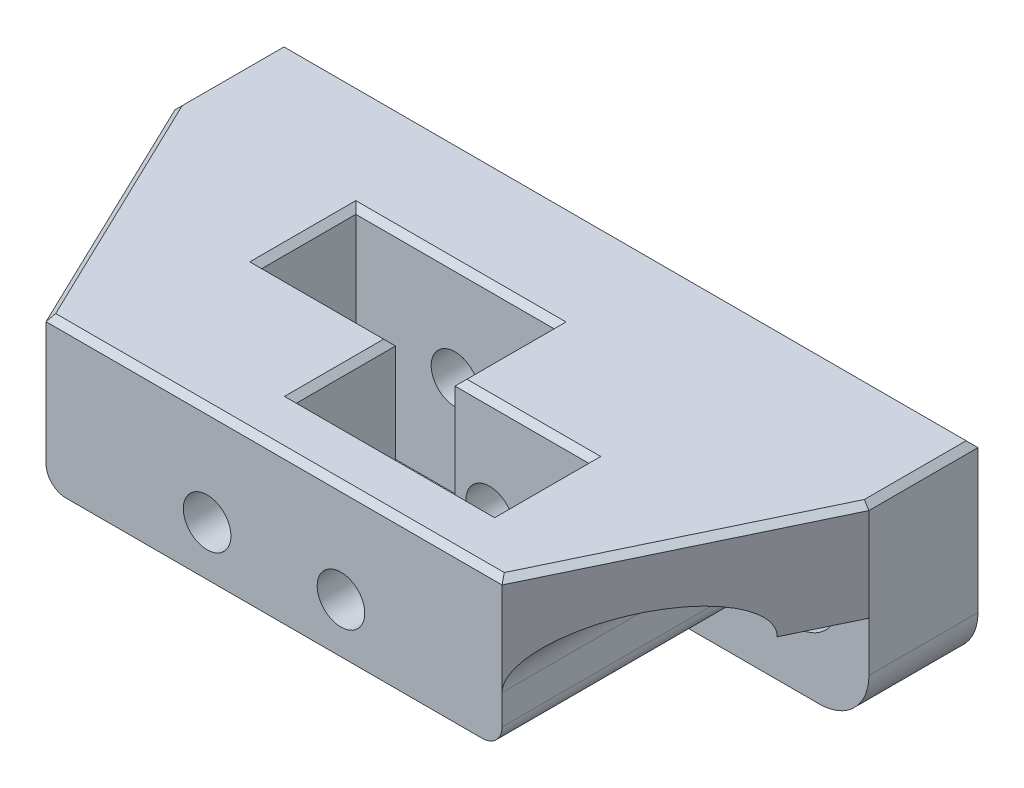
from build123d import *

# Parameters (mm, degrees)
SKETCH_1_W               = 70
SKETCH_1_H               = 20
EXTRUDE_1_DEPTH          = 11
SKETCH_3_W               = 70
SKETCH_3_H               = 15
EXTRUDE_2_DEPTH          = 25
CUT_EXTRUDE_1_DEPTH      = 15
SKETCH_5_R               = 4.5
CUT_EXTRUDE_2_DEPTH      = 30
SKETCH_11_R              = 2.6
CUT_EXTRUDE_7_DEPTH      = 6
SKETCH_12_W              = 12
SKETCH_12_H              = 5
CUT_EXTRUDE_8_DEPTH      = 25
SKETCH_8_R               = 2.4
CUT_EXTRUDE_5_DEPTH      = 31.5
CUT_EXTRUDE_5_DEPTH_BACK = 6.5
SKETCH_10_R              = 2.4
CUT_EXTRUDE_6_DEPTH      = 26
CUT_EXTRUDE_6_DEPTH_BACK = 12
FILLET_1_R               = 5
CHAMFER_1_SIZE           = 0.6
FILLET_2_R               = 2


with BuildPart() as part:
    # 草图1 → 凸台-拉伸1 (new body)
    with BuildSketch(Plane.XY):
        with Locations((21.875, 8.541666667)):
            Rectangle(SKETCH_1_W, SKETCH_1_H)
    extrude(amount=EXTRUDE_1_DEPTH)

    # 草图3 → 凸台-拉伸2 (add)
    with BuildSketch(Plane.XY.offset(11)):
        with Locations((21.875, 11.041666667)):
            Rectangle(SKETCH_3_W, SKETCH_3_H)
    extrude(amount=EXTRUDE_2_DEPTH)

    # 草图4 → 切除-拉伸1 (cut)
    with BuildSketch(Plane.XZ.offset(-3.541666667)):
        Polygon((-13.125, 36), (-13.125, 11), (-1.125, 36), align=None)
        Polygon((56.875, 11), (44.875, 36), (56.875, 36), align=None)
        Polygon((5.125, 11), (25.125, 11), (25.125, 21), (38.625, 21), (38.625, 30.5), (18.625, 30.5), (18.625, 21), (18.625, 20.5), (5.125, 20.5), align=None)
    extrude(amount=-CUT_EXTRUDE_1_DEPTH, mode=Mode.SUBTRACT)

    # 草图5 → 切除-拉伸2 (cut)
    with BuildSketch(Plane.XY.offset(36)):
        with Locations((-5.625, 8.541666667)):
            Circle(SKETCH_5_R)
        with Locations((49.375, 8.541666667)):
            Circle(SKETCH_5_R)
    extrude(amount=-CUT_EXTRUDE_2_DEPTH, mode=Mode.SUBTRACT)

    # 草图11 → 切除-拉伸7 (cut)
    with BuildSketch(Plane.XY.offset(6)):
        with Locations((-5.625, 8.541666667)):
            Circle(SKETCH_11_R)
        with Locations((49.375, 8.541666667)):
            Circle(SKETCH_11_R)
    extrude(amount=-CUT_EXTRUDE_7_DEPTH, mode=Mode.SUBTRACT)

    # 草图12 → 切除-拉伸8 (cut)
    with BuildSketch(Plane.XY.offset(36)):
        with Locations((-7.125, 6.041666667)):
            Rectangle(SKETCH_12_W, SKETCH_12_H)
        with Locations((50.875, 6.041666667)):
            Rectangle(SKETCH_12_W, SKETCH_12_H)
    extrude(amount=-CUT_EXTRUDE_8_DEPTH, mode=Mode.SUBTRACT)

    # 草图8 → 切除-拉伸5 (cut, two sides)
    with BuildSketch(Plane(origin=(0, 0, 30.5), x_dir=(-1, 0, 0), z_dir=(0, 0, -1))) as cut_extrude_5_sk:
        with Locations((-28.625, 8.541666667)):
            Circle(SKETCH_8_R)
    extrude(amount=CUT_EXTRUDE_5_DEPTH, mode=Mode.SUBTRACT)
    extrude(cut_extrude_5_sk.sketch, amount=-CUT_EXTRUDE_5_DEPTH_BACK, mode=Mode.SUBTRACT)

    # 草图10 → 切除-拉伸6 (cut, two sides)
    with BuildSketch(Plane.XY.offset(11)) as cut_extrude_6_sk:
        with Locations((15.125, 8.541666667)):
            Circle(SKETCH_10_R)
    extrude(amount=CUT_EXTRUDE_6_DEPTH, mode=Mode.SUBTRACT)
    extrude(cut_extrude_6_sk.sketch, amount=-CUT_EXTRUDE_6_DEPTH_BACK, mode=Mode.SUBTRACT)

    # 圆角1
    fillet_1_edges = [part.edges().sort_by_distance(p)[0] for p in [
        (56.875, -1.458333333, 5.5),
        (-13.125, -1.458333333, 5.5),
    ]]
    fillet(fillet_1_edges, radius=FILLET_1_R)

    # 倒角1
    chamfer_1_edges = [part.edges().sort_by_distance(p)[0] for p in [
        (21.875, 18.541666667, 36),
        (-13.125, 18.541666667, 5.5),
        (56.875, 18.541666667, 5.5),
        (-7.125, 18.541666667, 23.5),
        (50.875, 18.541666667, 23.5),
        (5.125, 18.541666667, 15.75),
        (11.875, 18.541666667, 20.5),
        (18.625, 18.541666667, 25.5),
        (21.875, 18.541666667, 0),
        (28.625, 18.541666667, 30.5),
        (38.625, 18.541666667, 25.75),
        (31.875, 18.541666667, 21),
        (25.125, 18.541666667, 16),
        (15.125, 18.541666667, 11),
    ]]
    chamfer(chamfer_1_edges, length=CHAMFER_1_SIZE)

    # 圆角2
    fillet_2_edges = [part.edges().sort_by_distance(p)[0] for p in [
        (-1.125, 3.541666667, 23.5),
        (44.875, 3.541666667, 23.5),
        (25.125, 3.541666667, 16),
        (18.625, 3.541666667, 25.5),
    ]]
    fillet(fillet_2_edges, radius=FILLET_2_R)


solid = part.part
